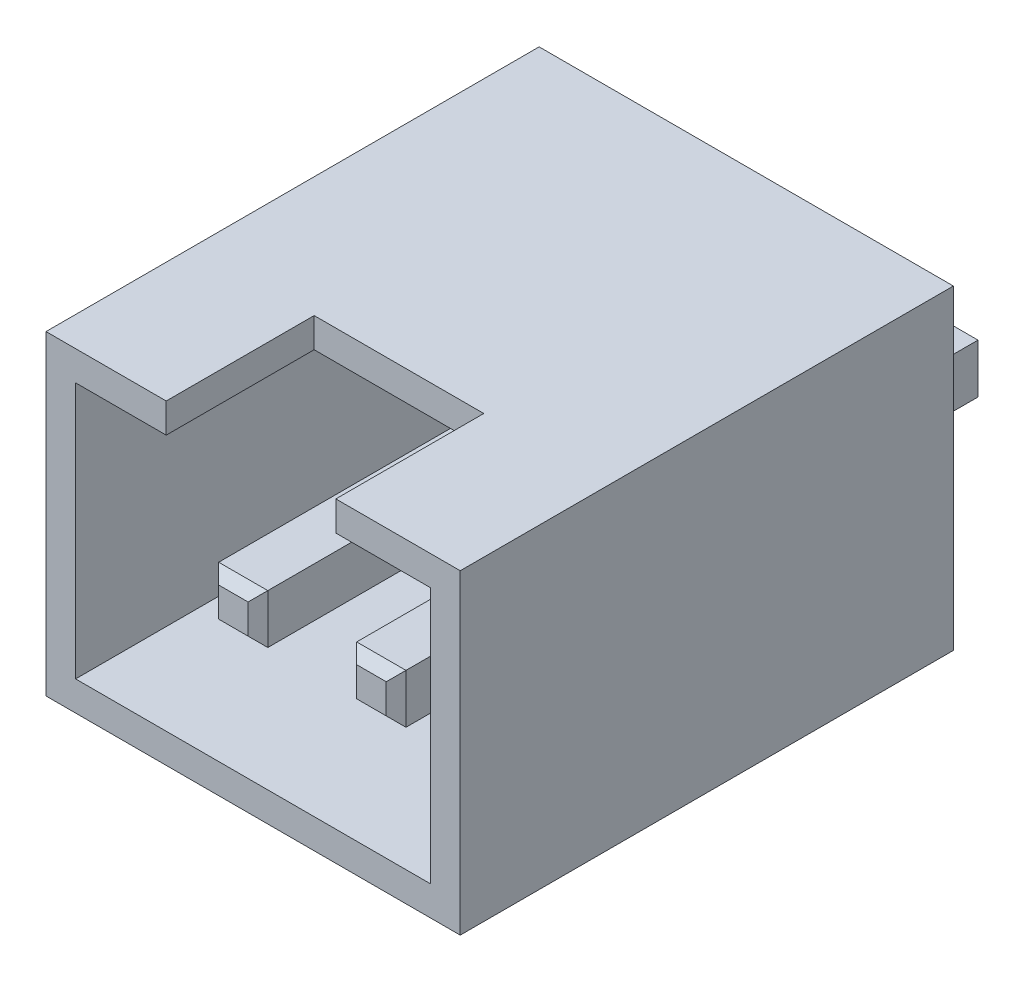
from build123d import *

# Parameters (mm, degrees)
SKETCH_1_W           = 4.2
SKETCH_1_H           = 3.2
EXTRUDE_1_DEPTH      = 5
SKETCH_2_W           = 3.6
SKETCH_2_H           = 2.6
CUT_EXTRUDE_2_DEPTH  = 4.5
SKETCH_10_W          = 1.719860591
SKETCH_10_H          = 0.3
CUT_EXTRUDE_6_DEPTH  = 1.5
SKETCH_12_W          = 0.497980778
SKETCH_12_H          = 0.499968878
SKETCH_12_W_2        = 0.49954636
EXTRUDE_2_DEPTH      = 4
EXTRUDE_2_DEPTH_BACK = 2
CHAMFER_2_SIZE       = 0.1
CHAMFER_3_SIZE       = 0.1


with BuildPart() as part:
    # 草图1 → 凸台-拉伸1 (new body)
    with BuildSketch(Plane.XY):
        Rectangle(SKETCH_1_W, SKETCH_1_H)
    extrude(amount=EXTRUDE_1_DEPTH)

    # 草图2 → 切除-拉伸2 (cut)
    with BuildSketch(Plane.XY.offset(5)):
        Rectangle(SKETCH_2_W, SKETCH_2_H)
    extrude(amount=-CUT_EXTRUDE_2_DEPTH, mode=Mode.SUBTRACT)

    # 草图10 → 切除-拉伸6 (cut)
    with BuildSketch(Plane.XY.offset(5)):
        with Locations((-0.021149262, 1.45)):
            Rectangle(SKETCH_10_W, SKETCH_10_H)
    extrude(amount=-CUT_EXTRUDE_6_DEPTH, mode=Mode.SUBTRACT)

    # 草图12 → 凸台-拉伸2 (add, two sides)
    with BuildSketch(Plane.XY.offset(0.5)) as extrude_2_sk:
        with Locations((-0.7, -0.4)):
            Rectangle(SKETCH_12_W, SKETCH_12_H)
        with Locations((0.7, -0.4)):
            Rectangle(SKETCH_12_W_2, SKETCH_12_H)
    extrude(amount=EXTRUDE_2_DEPTH)
    extrude(extrude_2_sk.sketch, amount=-EXTRUDE_2_DEPTH_BACK)

    # 倒角2
    chamfer_2_edges = [part.edges().sort_by_distance(p)[0] for p in [
        (-0.451009611, -0.4, 4.5),
        (-0.7, -0.150015561, 4.5),
        (-0.948990389, -0.4, 4.5),
        (-0.7, -0.649984439, 4.5),
        (0.94977318, -0.4, 4.5),
        (0.7, -0.150015561, 4.5),
        (0.45022682, -0.4, 4.5),
        (0.7, -0.649984439, 4.5),
    ]]
    chamfer(chamfer_2_edges, length=CHAMFER_2_SIZE)

    # 倒角3
    chamfer_3_edges = [part.edges().sort_by_distance(p)[0] for p in [
        (-0.451009611, -0.4, -1.5),
        (-0.7, -0.649984439, -1.5),
        (-0.948990389, -0.4, -1.5),
        (-0.7, -0.150015561, -1.5),
        (0.94977318, -0.4, -1.5),
        (0.7, -0.649984439, -1.5),
        (0.45022682, -0.4, -1.5),
        (0.7, -0.150015561, -1.5),
    ]]
    chamfer(chamfer_3_edges, length=CHAMFER_3_SIZE)


solid = part.part
